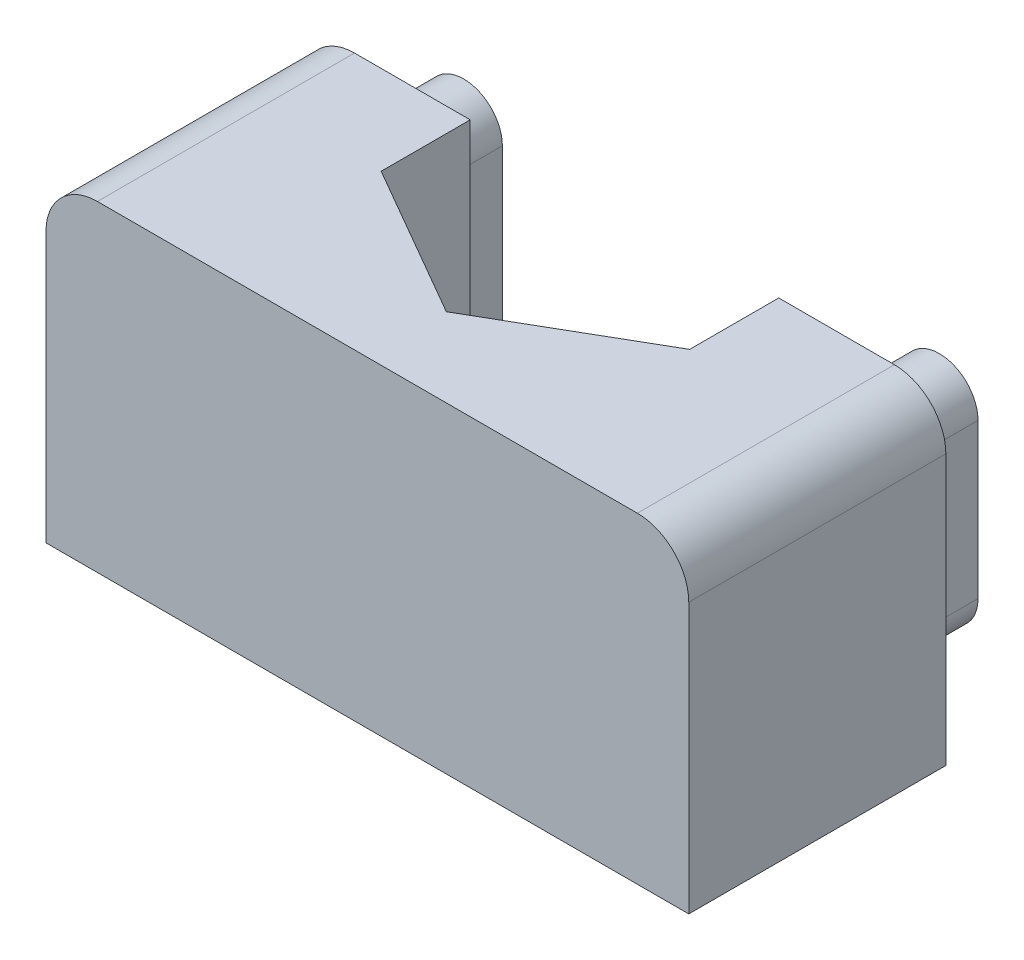
from build123d import *

# Parameters (mm, degrees)
BOSS_EXTRU_1_DEPTH      = 12.5
BOSS_EXTRU_1_DEPTH_BACK = 12.5
ESQUISSE3_W             = 25
ESQUISSE3_H             = 10
BOSS_EXTRU_2_DEPTH      = 12.5
ENL_V_MAT_EXTRU_3_DEPTH = 7.5
ESQUISSE5_R             = 5
ENL_V_MAT_EXTRU_4_DEPTH = 77.746335417
ESQUISSE6_W             = 73.841898386
ESQUISSE6_H             = 62.78176119
ENL_V_MAT_EXTRU_5_DEPTH = 79.198465458
BOSS_EXTRU_3_DEPTH      = 3
CONG_1_R                = 2


with BuildPart() as part:
    # Esquisse1 → Boss.-Extru.1 (new, two sides: drawn at the far end of the back side and taken through both)
    with BuildSketch(Plane(origin=(0, 0, 0), x_dir=(1, 0, 0), z_dir=(0, 1, 0)).offset(-BOSS_EXTRU_1_DEPTH_BACK)):
        with BuildLine():
            ThreePointArc((-8, 26), (-4.464466094, 24.535533906), (-3, 21))
            Line((-3, 21), (-3, -21))
            ThreePointArc((-3, -21), (-4.464466094, -24.535533906), (-8, -26))
            Line((-8, -26), (-63, -26))
            Line((-63, -26), (-63, -29))
            Line((-63, -29), (-3, -29))
            Line((-3, -29), (0, -29))
            Line((0, -29), (0, 29))
            Line((0, 29), (-3, 29))
            Line((-3, 29), (-63, 29))
            Line((-63, 29), (-63, 26))
            Line((-63, 26), (-8, 26))
        make_face()
    extrude(amount=BOSS_EXTRU_1_DEPTH + BOSS_EXTRU_1_DEPTH_BACK)

    # Esquisse3 → Boss.-Extru.2 (add)
    with BuildSketch(Plane(origin=(0, 0, 0), x_dir=(1, 0, 0), z_dir=(0, 1, 0))):
        with Locations((-12.5, 34)):
            Rectangle(ESQUISSE3_W, ESQUISSE3_H)
    extrude(amount=-BOSS_EXTRU_2_DEPTH)

    # Esquisse4 → Enlèv. mat.-Extru.3 (cut)
    with BuildSketch(Plane(origin=(0, 0, 0), x_dir=(1, 0, 0), z_dir=(0, 1, 0))):
        Polygon((-18.5, 39), (-6.5, 44), (-6.5, 35.535898385), (-12.5, 32.07179677), (-18.5, 35.535898385), align=None)
    extrude(amount=-ENL_V_MAT_EXTRU_3_DEPTH, mode=Mode.SUBTRACT)

    # Esquisse5 → Enlèv. mat.-Extru.4 (cut, through all)
    with BuildSketch(Plane(origin=(0, -7.5, 0), x_dir=(1, 0, 0), z_dir=(0, 1, 0))):
        with Locations((-12.5, 39)):
            Circle(ESQUISSE5_R)
    extrude(amount=-ENL_V_MAT_EXTRU_4_DEPTH, mode=Mode.SUBTRACT)

    # Esquisse6 → Enlèv. mat.-Extru.5 (cut, through all)
    with BuildSketch(Plane(origin=(0, 12.5, 0), x_dir=(1, 0, 0), z_dir=(0, 1, 0))):
        with Locations((-26.079050807, -2.390880595)):
            Rectangle(ESQUISSE6_W, ESQUISSE6_H)
    extrude(amount=-ENL_V_MAT_EXTRU_5_DEPTH, mode=Mode.SUBTRACT)

    # Esquisse7 → Boss.-Extru.3 (add)
    with BuildSketch(Plane(origin=(0, 0, -39), x_dir=(-1, 0, 0), z_dir=(0, 0, -1))):
        with BuildLine():
            Line((4.75, -3.25), (4.75, -9.25))
            ThreePointArc((4.75, -9.25), (3.25, -10.75), (1.75, -9.25))
            Line((1.75, -9.25), (1.75, -3.25))
            ThreePointArc((1.75, -3.25), (3.25, -1.75), (4.75, -3.25))
        make_face()
        with BuildLine():
            Line((20.25, -3.25), (20.25, -9.25))
            ThreePointArc((20.25, -9.25), (21.75, -10.75), (23.25, -9.25))
            Line((23.25, -9.25), (23.25, -3.25))
            ThreePointArc((23.25, -3.25), (21.75, -1.75), (20.25, -3.25))
        make_face()
    extrude(amount=BOSS_EXTRU_3_DEPTH)

    # Congé1
    cong_1_edges = [part.edges().sort_by_distance(p)[0] for p in [
        (0, 0, -34),
        (-25, 0, -34),
    ]]
    fillet(cong_1_edges, radius=CONG_1_R)


solid = part.part
